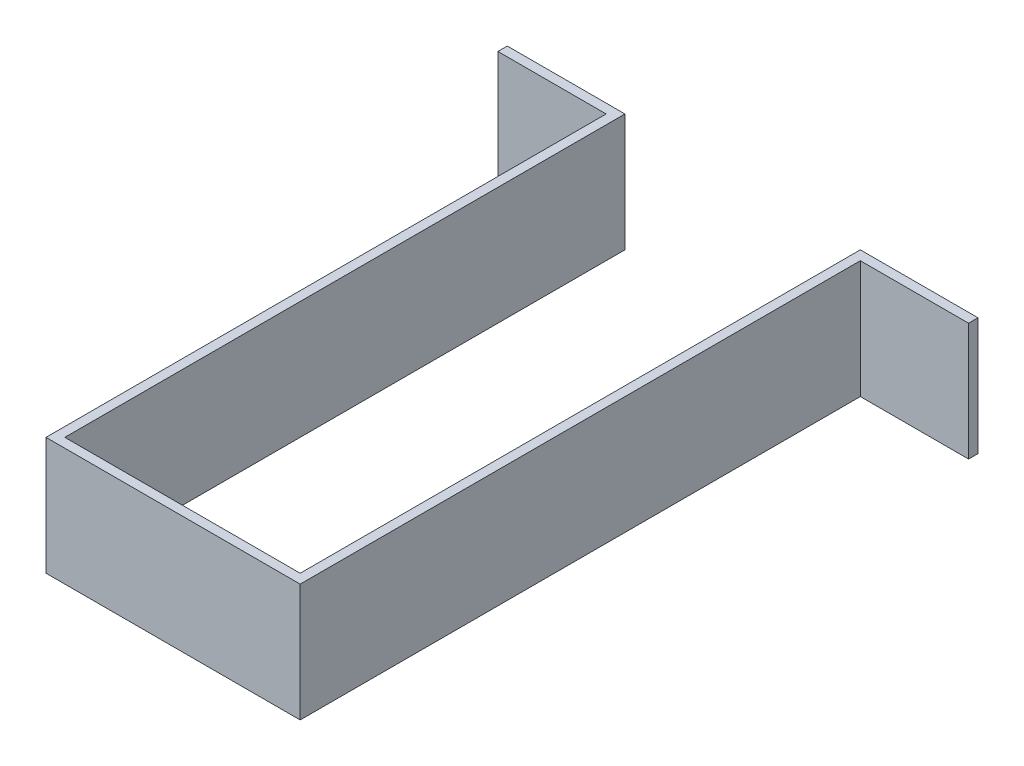
from build123d import *

# Parameters (mm, degrees)
BOSS_EXTRUDE1_DEPTH = 25


with BuildPart() as part:
    # Sketch2 → Boss-Extrude1 (new body)
    with BuildSketch(Plane(origin=(0, 0, 0), x_dir=(1, 0, 0), z_dir=(0, 1, 0))):
        Polygon((0, 0), (0, 119), (-25, 119), (-25, 117), (-2, 117), (-2, -2), (52, -2), (52, 117), (75, 117), (75, 119), (50, 119), (50, 0), align=None)
    extrude(amount=-BOSS_EXTRUDE1_DEPTH)


solid = part.part
